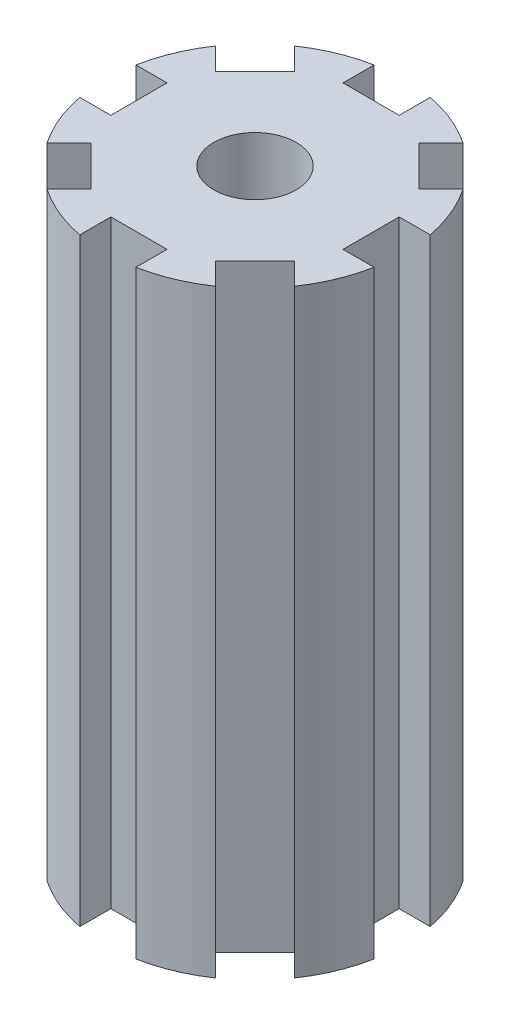
from build123d import *

# Parameters (mm, degrees)
SKETCH1_R           = 12.7
BOSS_EXTRUDE1_DEPTH = 50.8
SKETCH2_R           = 3.4925
SKETCH2_W           = 4.7625
SKETCH2_H           = 5.715
SKETCH2_W_2         = 5.715
SKETCH2_H_2         = 4.7625
CUT_EXTRUDE1_DEPTH  = 109.22


with BuildPart() as part:
    # Sketch1 → Boss-Extrude1 (new body)
    with BuildSketch(Plane(origin=(0, 0, 0), x_dir=(0, 0, -1), z_dir=(0, 1, 0))):
        Circle(SKETCH1_R)
    extrude(amount=-BOSS_EXTRUDE1_DEPTH)

    # Sketch2 → Cut-Extrude1 (cut)
    with BuildSketch(Plane(origin=(0, 0, 0), x_dir=(0, 0, -1), z_dir=(0, 1, 0))):
        Circle(SKETCH2_R)
        Polygon((12.684611771, 9.317015726), (9.317015726, 12.684611771), (5.275900471, 8.643496517), (8.643496517, 5.275900471), align=None)
        with Locations((0, 12.7)):
            Rectangle(SKETCH2_W, SKETCH2_H)
        with Locations((12.7, 0)):
            Rectangle(SKETCH2_W_2, SKETCH2_H_2)
        Polygon((9.317015726, -12.684611771), (12.684611771, -9.317015726), (8.643496517, -5.275900471), (5.275900471, -8.643496517), align=None)
        with Locations((0, -12.7)):
            Rectangle(SKETCH2_W, SKETCH2_H)
        Polygon((-12.684611771, -9.317015726), (-9.317015726, -12.684611771), (-5.275900471, -8.643496517), (-8.643496517, -5.275900471), align=None)
        with Locations((-12.7, 0)):
            Rectangle(SKETCH2_W_2, SKETCH2_H_2)
        Polygon((-9.317015726, 12.684611771), (-12.684611771, 9.317015726), (-8.643496517, 5.275900471), (-5.275900471, 8.643496517), align=None)
    extrude(amount=-CUT_EXTRUDE1_DEPTH, mode=Mode.SUBTRACT)


solid = part.part
